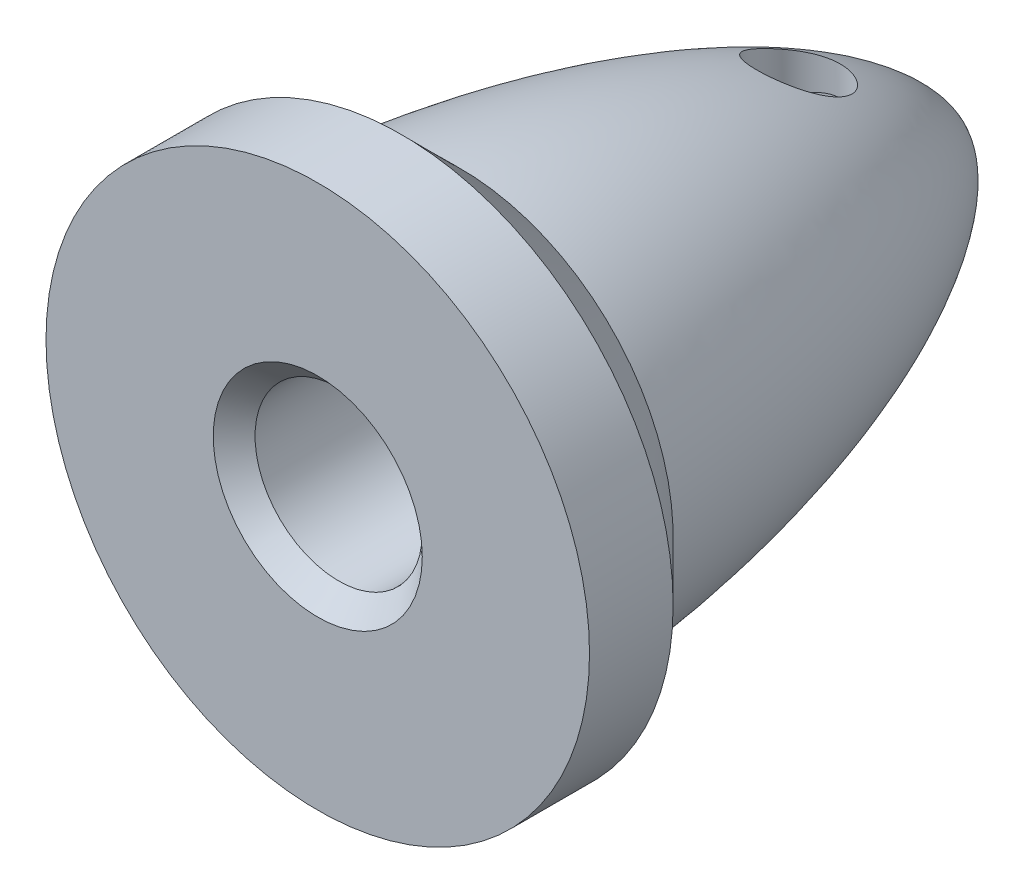
from build123d import *

# Parameters (mm, degrees)
CROQUIS2_R            = 0.99756867
CORTAR_EXTRUIR1_DEPTH = 5
CROQUIS4_R            = 2
CORTAR_EXTRUIR2_DEPTH = 13.5
CHAFL_N1_SIZE         = 0.5


with BuildPart() as part:
    # Croquis1 → Revolución1 (revolve)
    with BuildSketch(Plane(origin=(0, 0, 0), x_dir=(1, 0, 0), z_dir=(0, 1, 0))):
        with BuildLine():
            Line((0, -7.6), (-6.5, -7.6))
            Line((-6.5, -7.6), (-6.5, -5.6))
            Line((-6.5, -5.6), (-5.085786438, -4.185786438))
            add(Edge.make_bspline(
                [(-5.085786438, -4.185786438), (-4.45743914, 2.686299208), (-1.971742684, 7.41138075), (0, 7.6)],
                knots=[0, 0, 0, 0, 1, 1, 1, 1], degree=3))
            Line((0, 7.6), (0, -7.6))
        make_face()
    revolve(axis=Axis((0, 0, -14.344827586), (0, 0, 1)))

    # Croquis2 → Cortar-Extruir1 (cut, symmetric)
    with BuildSketch(Plane(origin=(0, 0, 0), x_dir=(1, 0, 0), z_dir=(0, 1, 0))):
        with Locations((0, 3.9)):
            Circle(CROQUIS2_R)
    extrude(amount=CORTAR_EXTRUIR1_DEPTH, both=True, mode=Mode.SUBTRACT)

    # Croquis4 → Cortar-Extruir2 (cut)
    with BuildSketch(Plane.XY.offset(7.6)):
        Circle(CROQUIS4_R)
    extrude(amount=-CORTAR_EXTRUIR2_DEPTH, mode=Mode.SUBTRACT)

    # Chaflán1
    chafl_n1_edges = [part.edges().sort_by_distance(p)[0] for p in [
        (-2, 0, 7.6),
    ]]
    chamfer(chafl_n1_edges, length=CHAFL_N1_SIZE)


solid = part.part
